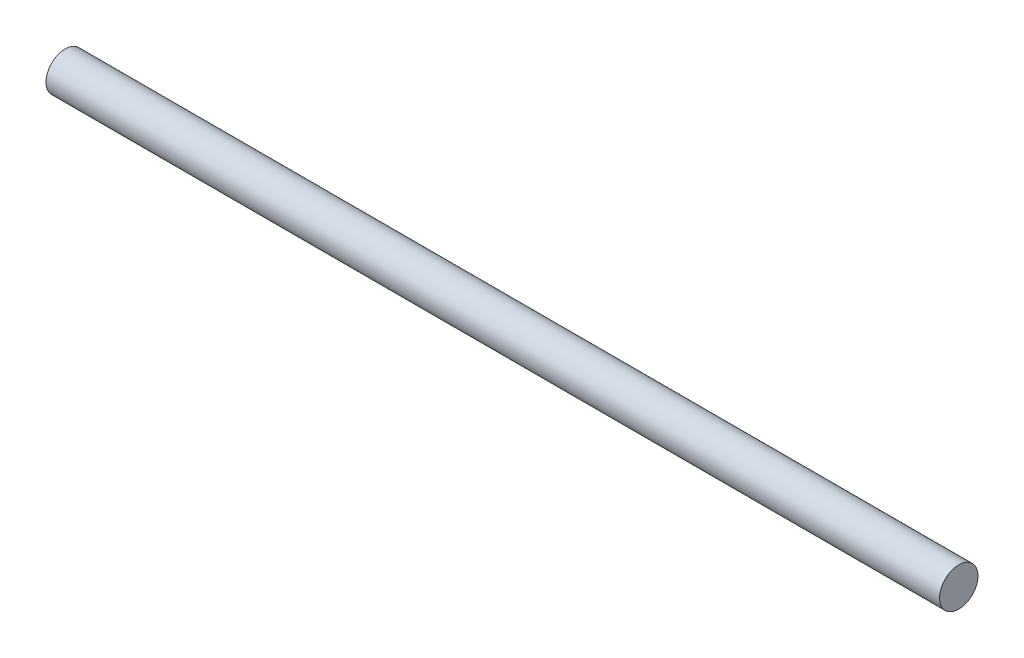
from build123d import *

# Parameters (mm, degrees)
SKETCH1_R           = 6.35
BOSS_EXTRUDE1_DEPTH = 295.275


with BuildPart() as part:
    # Sketch1 → Boss-Extrude1 (new body)
    with BuildSketch(Plane(origin=(0, 0, 0), x_dir=(0, 0, -1), z_dir=(1, 0, 0))):
        Circle(SKETCH1_R)
    extrude(amount=BOSS_EXTRUDE1_DEPTH)


solid = part.part
